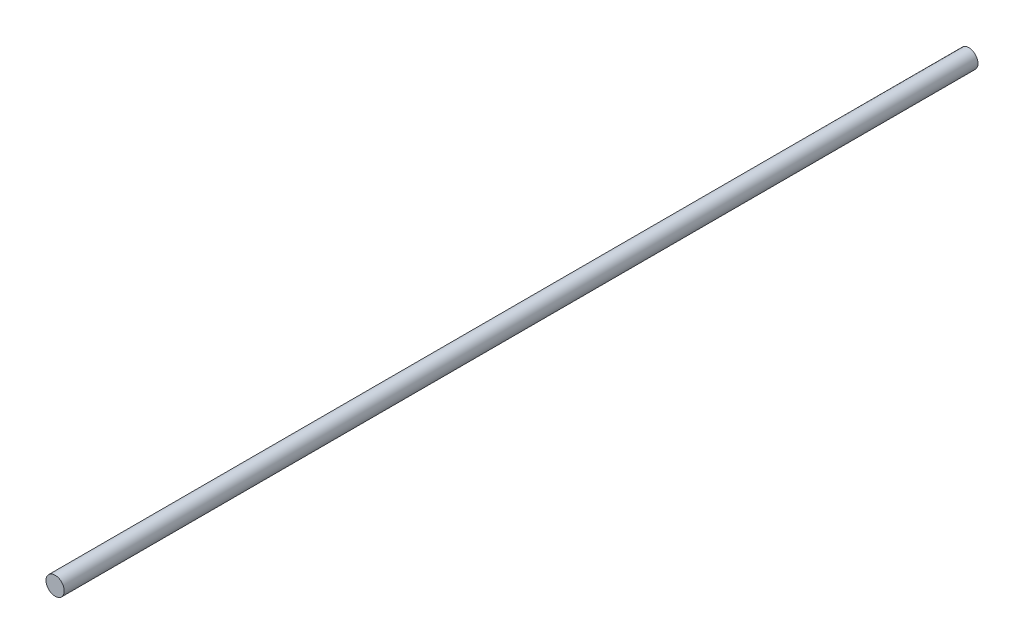
from build123d import *

# Parameters (mm, degrees)
SKETCH1_R           = 2.5
BOSS_EXTRUDE1_DEPTH = 250


with BuildPart() as part:
    # Sketch1 → Boss-Extrude1 (new body)
    with BuildSketch(Plane.XY):
        Circle(SKETCH1_R)
    extrude(amount=BOSS_EXTRUDE1_DEPTH)


solid = part.part
